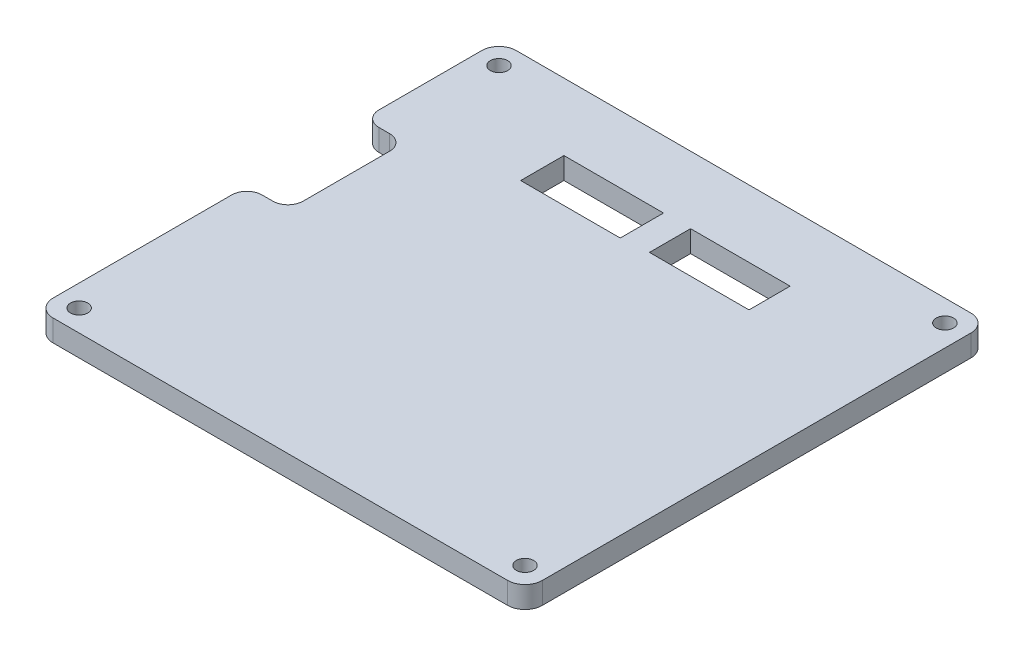
from build123d import *

# Parameters (mm, degrees)
SKETCH1_W                  = 113
SKETCH1_H                  = 107
MAIN_BODY_BACK_PLATE_DEPTH = 5
HEIGHT_ADJUST_DEPTH        = 20
SKETCH4_W                  = 23
SKETCH4_H                  = 10
SKETCH4_H_2                = 9.5
HOLE_POSTITIONS_DEPTH      = 40
SKETCH5_R                  = 2
SCREW_HOLES_DEPTH          = 10.59530888
FILLET1_R                  = 4
SKETCH6_W                  = 9.5
SKETCH6_H                  = 27
CUT_EXTRUDE1_DEPTH         = 10
FILLET2_R                  = 3.5


with BuildPart() as part:
    # Sketch1 → Main Body Back Plate (new body)
    with BuildSketch(Plane(origin=(0, 0, 0), x_dir=(1, 0, 0), z_dir=(0, 1, 0))):
        Rectangle(SKETCH1_W, SKETCH1_H)
    extrude(amount=MAIN_BODY_BACK_PLATE_DEPTH)

    # Sketch3 → Height Adjust (add, symmetric)
    with BuildSketch(Plane.ZY):
        Polygon((33.5, 0), (33.5, -4.59530888), (53.5, 0), align=None)
    extrude(amount=HEIGHT_ADJUST_DEPTH, both=True)

    # Sketch4 → Hole Postitions (cut)
    with BuildSketch(Plane(origin=(0, 5, 0), x_dir=(1, 0, 0), z_dir=(0, 1, 0))):
        with Locations((-14.5, 33)):
            Rectangle(SKETCH4_W, SKETCH4_H)
        with Locations((14.75, 33.25)):
            Rectangle(SKETCH4_W, SKETCH4_H_2)
    extrude(amount=-HOLE_POSTITIONS_DEPTH, mode=Mode.SUBTRACT)

    # Sketch5 → Screw Holes (cut, through all)
    with BuildSketch(Plane(origin=(0, 5, 0), x_dir=(1, 0, 0), z_dir=(0, 1, 0))):
        with Locations((-51.5, 48.5)):
            Circle(SKETCH5_R)
        with Locations((-51.5, -48.5)):
            Circle(SKETCH5_R)
        with Locations((51.5, -48.5)):
            Circle(SKETCH5_R)
        with Locations((51.5, 48.5)):
            Circle(SKETCH5_R)
    extrude(amount=-SCREW_HOLES_DEPTH, mode=Mode.SUBTRACT)

    # Fillet1
    fillet1_edges = [part.edges().sort_by_distance(p)[0] for p in [
        (56.5, 2.5, 53.5),
        (-56.5, 2.5, 53.5),
        (-56.5, 2.5, -53.5),
        (56.5, 2.5, -53.5),
    ]]
    fillet(fillet1_edges, radius=FILLET1_R)

    # Sketch6 → Cut-Extrude1 (cut)
    with BuildSketch(Plane.XZ):
        with Locations((-51.75, -8.75)):
            Rectangle(SKETCH6_W, SKETCH6_H)
    extrude(amount=-CUT_EXTRUDE1_DEPTH, mode=Mode.SUBTRACT)

    # Fillet2
    fillet2_edges = [part.edges().sort_by_distance(p)[0] for p in [
        (-56.5, 2.5, -22.25),
        (-56.5, 2.5, 4.75),
        (-47, 2.5, 4.75),
        (-47, 2.5, -22.25),
    ]]
    fillet(fillet2_edges, radius=FILLET2_R)


solid = part.part
